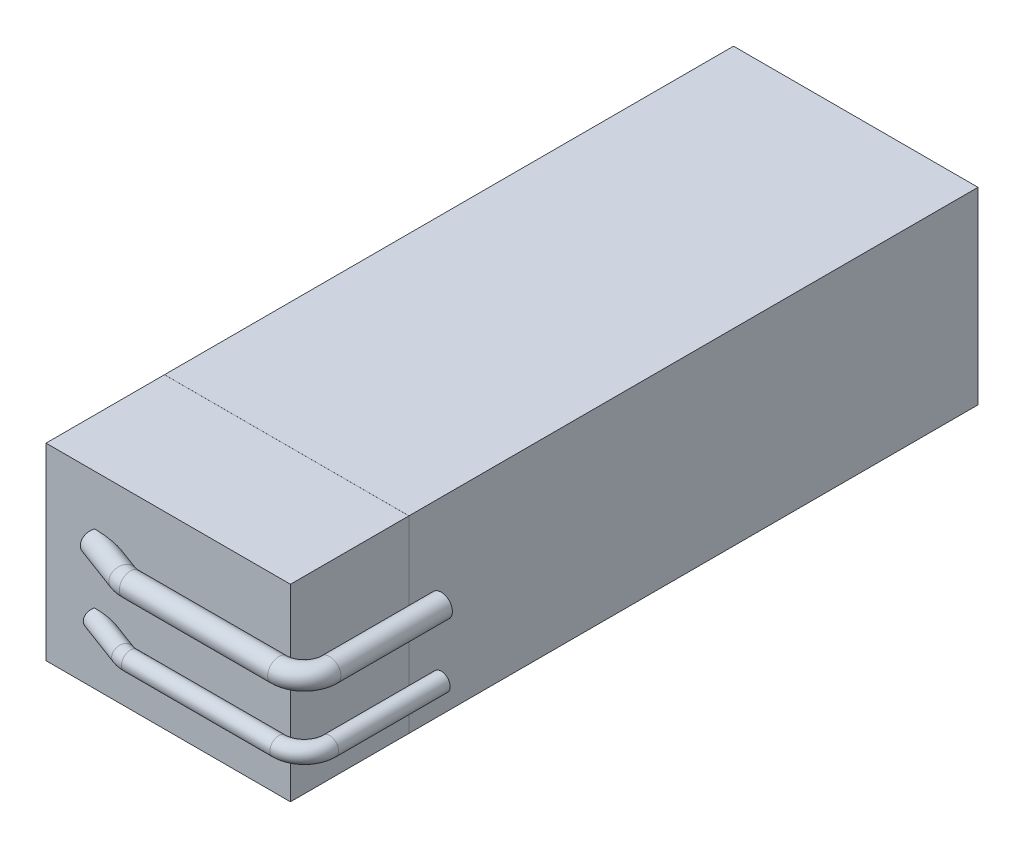
from build123d import *

# Parameters (mm, degrees)
ESQUISSE1_W             = 135
ESQUISSE1_H             = 37
BOSS_EXTRU_1_DEPTH      = 48
ESQUISSE3_R             = 1.75
ESQUISSE3_R_2           = 2.187725201
ESQUISSE4_W             = 48
ESQUISSE4_H             = 37
ENL_V_MAT_EXTRU_1_DEPTH = 0.01


with BuildPart() as part:
    # Esquisse1 → Boss.-Extru.1 (new body)
    with BuildSketch(Plane(origin=(0, 0, 0), x_dir=(0, 0, -1), z_dir=(1, 0, 0))):
        with Locations((-67.5, 18.5)):
            Rectangle(ESQUISSE1_W, ESQUISSE1_H)
    extrude(amount=BOSS_EXTRU_1_DEPTH)

    # Balayage1: sweep along a path in Esquisse2
    with BuildLine(Plane(origin=(0, 12, 0), x_dir=(-1, 0, 0), z_dir=(0, -1, 0))) as balayage1_path:
        Line((-54.342429432, -111.732100004), (-54.342429432, -133.627216376))
        ThreePointArc((-54.342429432, -133.627216376), (-52.877963338, -137.162750282), (-49.342429432, -138.627216376))
        Line((-49.342429432, -138.627216376), (-20.202133269, -138.627216376))
        ThreePointArc((-20.202133269, -138.627216376), (-19.315749698, -138.548021612), (-18.457444903, -138.312946043))
        Line((-18.457444903, -138.312946043), (-9.559827507, -135))
    # Esquisse3 → Balayage1 (sweep)
    with BuildSketch(Plane(origin=(0, 0, 111.732100004), x_dir=(-1, 0, 0), z_dir=(0, 0, -1))):
        with Locations((-54.342429432, 12)):
            Circle(ESQUISSE3_R)
        with Locations((-54.342429432, 25)):
            Circle(ESQUISSE3_R_2)
    sweep(path=balayage1_path.line)

    # Esquisse4 → Enlèv. mat.-Extru.1 (cut)
    with BuildSketch(Plane(origin=(0, 0, 111.732100004), x_dir=(-1, 0, 0), z_dir=(0, 0, -1))):
        with Locations((-24, 18.5)):
            Rectangle(ESQUISSE4_W, ESQUISSE4_H)
    extrude(amount=-ENL_V_MAT_EXTRU_1_DEPTH, mode=Mode.SUBTRACT)


solid = part.part
